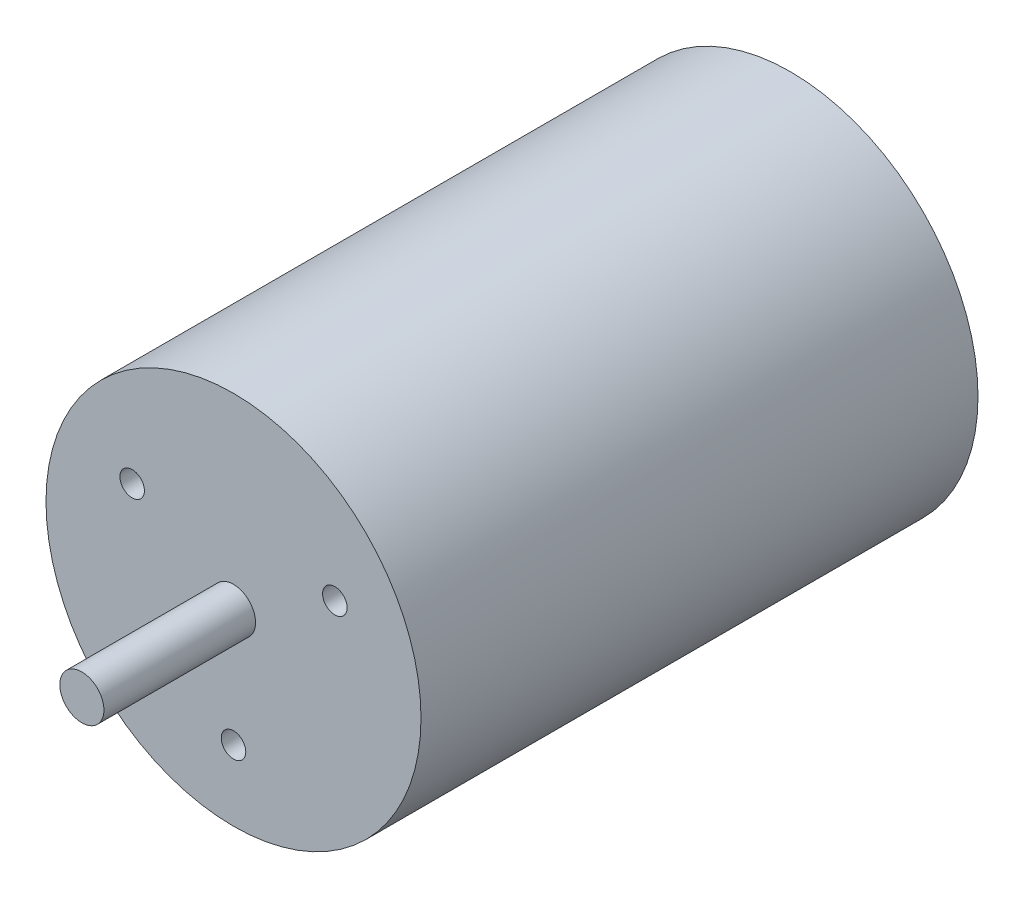
from build123d import *

# Parameters (mm, degrees)
SKETCH1_R           = 34
BOSS_EXTRUDE1_DEPTH = 101
SKETCH2_R           = 4
BOSS_EXTRUDE2_DEPTH = 27.5
SKETCH3_R           = 2.225
CUT_EXTRUDE1_DEPTH  = 20
SKETCH4_R           = 14
BOSS_EXTRUDE3_DEPTH = 7


with BuildPart() as part:
    # Sketch1 → Boss-Extrude1 (new body)
    with BuildSketch(Plane.XY):
        Circle(SKETCH1_R)
    extrude(amount=BOSS_EXTRUDE1_DEPTH)

    # Sketch2 → Boss-Extrude2 (add)
    with BuildSketch(Plane.XY.offset(101)):
        Circle(SKETCH2_R)
    extrude(amount=BOSS_EXTRUDE2_DEPTH)

    # Sketch3 → Cut-Extrude1 (cut)
    with BuildSketch(Plane.XY.offset(101)):
        with Locations((-18.375, 10.608811196)):
            Circle(SKETCH3_R)
        with Locations((18.375, 10.608811196)):
            Circle(SKETCH3_R)
        with Locations((0, -21.217622393)):
            Circle(SKETCH3_R)
    extrude(amount=-CUT_EXTRUDE1_DEPTH, mode=Mode.SUBTRACT)

    # Sketch4 → Boss-Extrude3 (add)
    with BuildSketch(Plane(origin=(0, 0, 0), x_dir=(-1, 0, 0), z_dir=(0, 0, -1))):
        Circle(SKETCH4_R)
    extrude(amount=BOSS_EXTRUDE3_DEPTH)


solid = part.part
